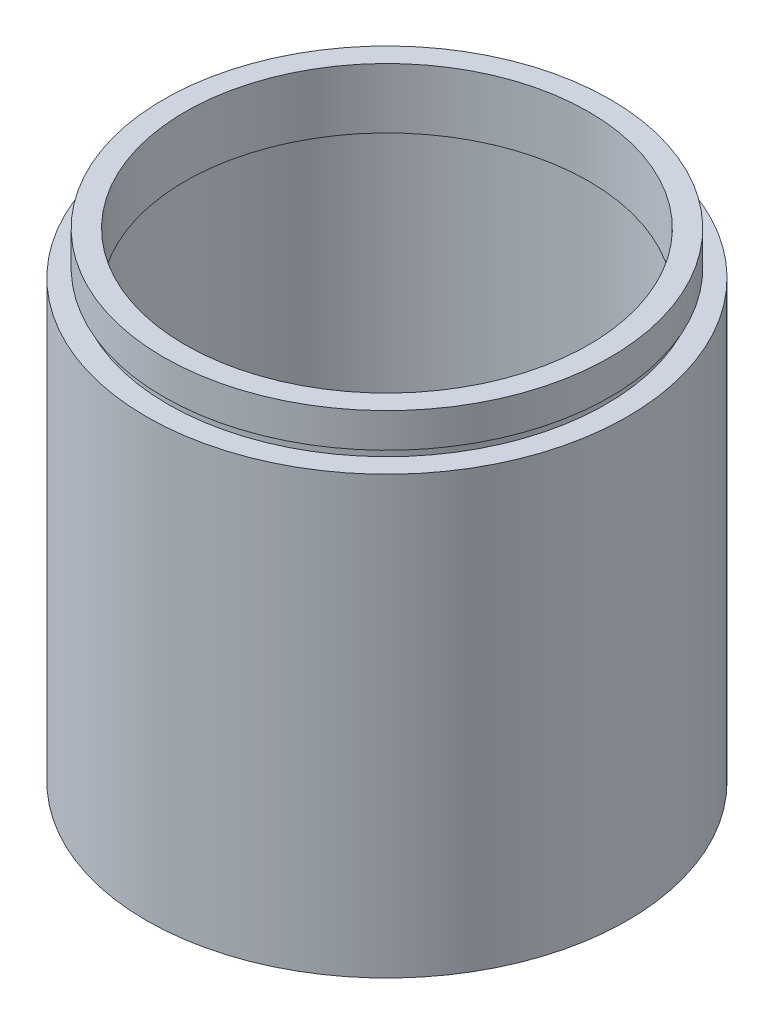
from build123d import *


with BuildPart() as part:
    # 草图1 → 旋转1 (revolve)
    with BuildSketch(Plane.XY, mode=Mode.PRIVATE) as revolve_1_sk:
        Polygon((23.5, 55.8), (26, 55.8), (26, 51.8), (25.5, 51.8), (25.5, 50.8), (28, 50.8), (28, 0), (25.5, 0), (25.5, 47.8), (26.1, 47.8), (26.1, 48.8), (23.5, 48.8), align=None)
    revolve(revolve_1_sk.sketch.rotate(Axis((0, 161.376166943, 0), (0, -1, 0)), 90), axis=Axis((0, 161.376166943, 0), (0, -1, 0)))  # turned: the seam where the file's is


solid = part.part
